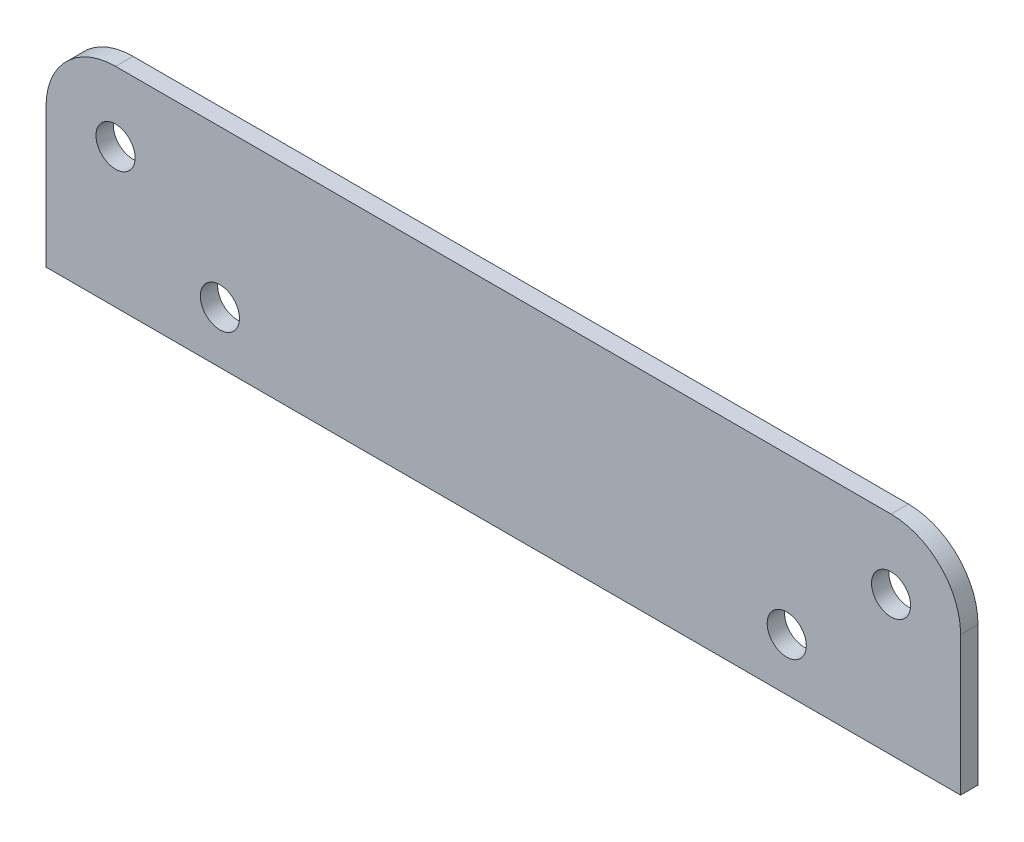
from build123d import *

# Parameters (mm, degrees)
SKETCH1_W                   = 167.005
SKETCH1_H                   = 38.1
BOSS_EXTRUDE1_DEPTH         = 3.175
FILLET1_R                   = 12.7
F_1_4_CLEARANCE_HOLE1_D     = 7.14248
F_1_4_CLEARANCE_HOLE1_DEPTH = 3.175


with BuildPart() as part:
    # Sketch1 → Boss-Extrude1 (new body)
    with BuildSketch(Plane.XY):
        with Locations((0, -1694.09345438)):
            Rectangle(SKETCH1_W, SKETCH1_H)
    extrude(amount=BOSS_EXTRUDE1_DEPTH)

    # Fillet1
    fillet1_edges = [part.edges().sort_by_distance(p)[0] for p in [
        (-83.5025, -1675.04345438, 1.5875),
        (83.5025, -1675.04345438, 1.5875),
    ]]
    fillet(fillet1_edges, radius=FILLET1_R)

    # 1/4 Clearance Hole1
    with Locations(Plane.XY.offset(3.175)):
        with Locations((-70.8025, -1687.74345438), (70.8025, -1687.74345438), (51.7525, -1703.61845438), (-51.7525, -1703.61845438)):
            Hole(F_1_4_CLEARANCE_HOLE1_D / 2, depth=F_1_4_CLEARANCE_HOLE1_DEPTH)


solid = part.part
